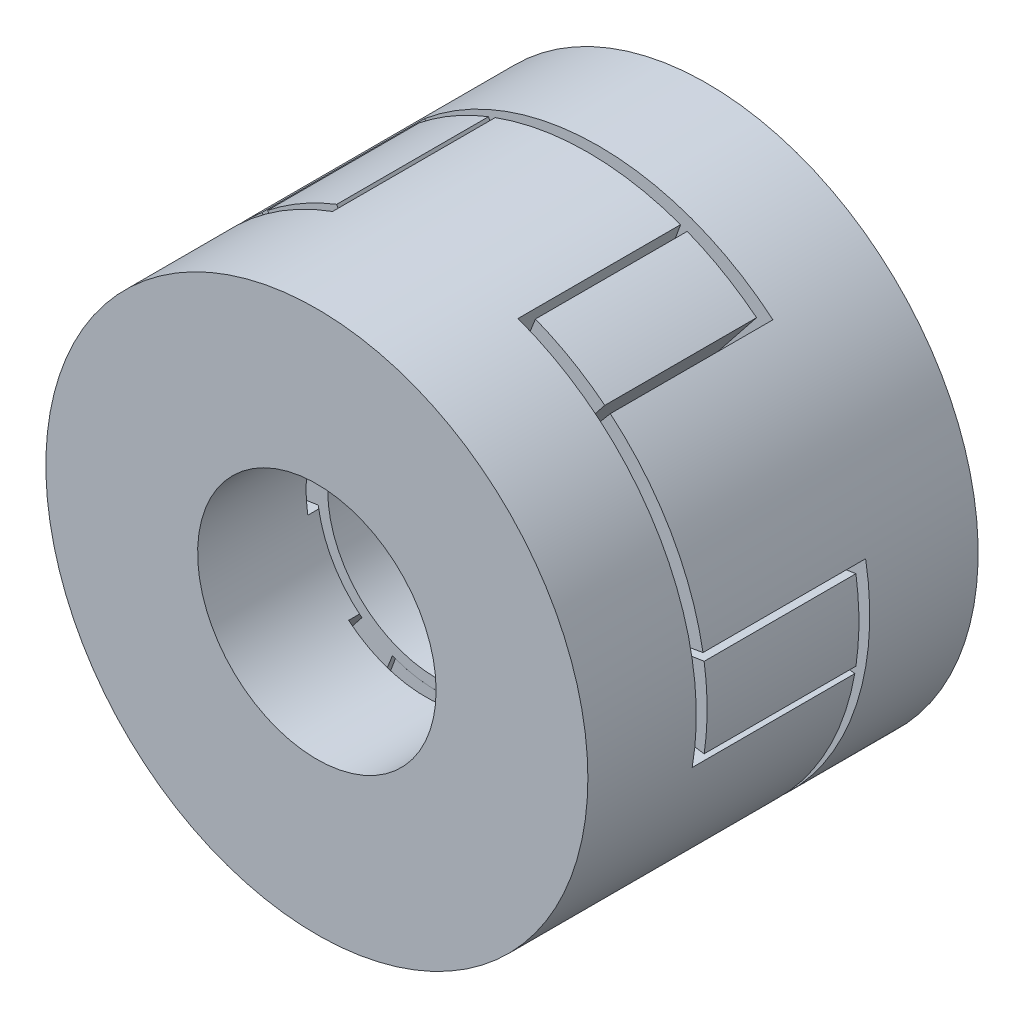
from build123d import *

# Parameters (mm, degrees)
SKETCH_1_R          = 25
SKETCH_1_R_2        = 11
EXTRUDE_1_DEPTH     = 25
CUT_EXTRUDE_1_DEPTH = 15
SKETCH_3_R          = 25
SKETCH_3_R_2        = 11
EXTRUDE_3_DEPTH     = 25
CUT_EXTRUDE_2_DEPTH = 15
SKETCH_5_R          = 25
SKETCH_5_R_2        = 10
EXTRUDE_5_DEPTH     = 14
CUT_EXTRUDE_5_DEPTH = 14


with BuildPart() as part:
    # 草图1 → 凸台-拉伸1 (new body)
    with BuildSketch(Plane.XY):
        Circle(SKETCH_1_R)
        Circle(SKETCH_1_R_2, mode=Mode.SUBTRACT)
    extrude(amount=EXTRUDE_1_DEPTH)

    # 草图2 → 切除-拉伸1 (cut)
    with BuildSketch(Plane(origin=(0, 0, 0), x_dir=(-1, 0, 0), z_dir=(0, 0, -1))):
        with BuildLine():
            Line((-24.620193825, -4.341204442), (-10.832885283, -1.910129954))
            ThreePointArc((-10.832885283, -1.910129954), (-9.526279442, 5.5), (-3.762221577, 10.336618829))
            Line((-3.762221577, 10.336618829), (-8.550503583, 23.49231552))
            ThreePointArc((-8.550503583, 23.49231552), (-16.069690273, 19.151111052), (-21.650635135, 12.49999993))
            ThreePointArc((-21.650635135, 12.49999993), (-24.620193832, 4.341204402), (-24.620193825, -4.341204442))
        make_face()
        with BuildLine():
            Line((8.550503583, 23.49231552), (3.762221577, 10.336618829))
            ThreePointArc((3.762221577, 10.336618829), (9.010672487, 6.3093408), (11, 0))
            ThreePointArc((11, 0), (10.958141679, -0.95871317), (10.832885283, -1.910129954))
            Line((10.832885283, -1.910129954), (24.620193825, -4.341204442))
            ThreePointArc((24.620193825, -4.341204442), (24.904867452, -2.178893569), (25, 0))
            ThreePointArc((25, 0), (24.148145619, 6.470476269), (21.650634949, 12.500000253))
            ThreePointArc((21.650634949, 12.500000253), (16.06969013, 19.151111172), (8.550503583, 23.49231552))
        make_face()
        with BuildLine():
            ThreePointArc((0, -11), (-3.762221577, -10.336618829), (-7.070663707, -8.426488874))
            Line((-7.070663707, -8.426488874), (-16.069690242, -19.151111078))
            ThreePointArc((-16.069690242, -19.151111078), (-8.550503583, -23.49231552), (0, -25))
            Line((0, -25), (0, -11))
        make_face()
        with BuildLine():
            Line((16.069690242, -19.151111078), (7.070663707, -8.426488874))
            ThreePointArc((7.070663707, -8.426488874), (3.762221577, -10.336618829), (0, -11))
            Line((0, -11), (0, -25))
            ThreePointArc((0, -25), (8.550503583, -23.49231552), (16.069690242, -19.151111078))
        make_face()
    extrude(amount=-CUT_EXTRUDE_1_DEPTH, mode=Mode.SUBTRACT)


with BuildPart() as body_2:
    # 草图3 → 凸台-拉伸3 (new body)
    with BuildSketch(Plane(origin=(0, 0, 14), x_dir=(-1, 0, 0), z_dir=(0, 0, -1))):
        Circle(SKETCH_3_R)
        Circle(SKETCH_3_R_2, mode=Mode.SUBTRACT)
    extrude(amount=EXTRUDE_3_DEPTH)

    # 草图4 → 切除-拉伸2 (cut)
    with BuildSketch(Plane.XY.offset(14)):
        with BuildLine():
            Line((-16.069690242, 19.151111078), (-7.070663707, 8.426488874))
            ThreePointArc((-7.070663707, 8.426488874), (-3.762221577, 10.336618829), (0, 11))
            Line((0, 11), (0, 25))
            ThreePointArc((0, 25), (-8.550503583, 23.49231552), (-16.069690242, 19.151111078))
        make_face()
        with BuildLine():
            ThreePointArc((0, 11), (3.762221577, 10.336618829), (7.070663707, 8.426488874))
            Line((7.070663707, 8.426488874), (16.069690242, 19.151111078))
            ThreePointArc((16.069690242, 19.151111078), (8.550503583, 23.49231552), (0, 25))
            Line((0, 25), (0, 11))
        make_face()
        with BuildLine():
            Line((24.620193825, 4.341204442), (10.832885283, 1.910129954))
            ThreePointArc((10.832885283, 1.910129954), (10.958141679, 0.95871317), (11, 0))
            ThreePointArc((11, 0), (9.010672487, -6.3093408), (3.762221577, -10.336618829))
            Line((3.762221577, -10.336618829), (8.550503583, -23.49231552))
            ThreePointArc((8.550503583, -23.49231552), (16.06969013, -19.151111172), (21.650634948, -12.500000253))
            ThreePointArc((21.650634948, -12.500000253), (24.148145619, -6.470476269), (25, 0))
            ThreePointArc((25, 0), (24.904867452, 2.178893569), (24.620193825, 4.341204442))
        make_face()
        with BuildLine():
            Line((-8.550503583, -23.49231552), (-3.762221577, -10.336618829))
            ThreePointArc((-3.762221577, -10.336618829), (-9.526279442, -5.5), (-10.832885283, 1.910129954))
            Line((-10.832885283, 1.910129954), (-24.620193825, 4.341204442))
            ThreePointArc((-24.620193825, 4.341204442), (-24.620193881, -4.341204125), (-21.650635416, -12.499999443))
            ThreePointArc((-21.650635416, -12.499999443), (-16.069690489, -19.151110871), (-8.550503583, -23.49231552))
        make_face()
    extrude(amount=-CUT_EXTRUDE_2_DEPTH, mode=Mode.SUBTRACT)


with BuildPart() as body_3:
    # 草图5 → 凸台-拉伸5 (new body)
    with BuildSketch(Plane(origin=(0, 0, 14), x_dir=(-1, 0, 0), z_dir=(0, 0, -1))):
        Circle(SKETCH_5_R)
        Circle(SKETCH_5_R_2, mode=Mode.SUBTRACT)
    extrude(amount=EXTRUDE_5_DEPTH)

    # 草图6 → 切除-拉伸5 (cut)
    with BuildSketch(Plane(origin=(0, 0, 0), x_dir=(-1, 0, 0), z_dir=(0, 0, -1))):
        with BuildLine():
            Line((-24.725396584, 3.695235278), (-10.879174497, 1.625903522))
            ThreePointArc((-10.879174497, 1.625903522), (-9.526279442, 5.5), (-6.847661003, 8.608689725))
            Line((-6.847661003, 8.608689725), (-15.562865916, 19.565203921))
            ThreePointArc((-15.562865916, 19.565203921), (-18.939124752, 16.318993647), (-21.650635312, 12.499999623))
            ThreePointArc((-21.650635312, 12.499999623), (-23.602225582, 8.242265926), (-24.725396584, 3.695235278))
        make_face()
        with BuildLine():
            Line((-9.162530668, 23.2604392), (-4.031513494, 10.234593248))
            ThreePointArc((-4.031513494, 10.234593248), (-2.051764396, 10.806954375), (0, 11))
            Line((0, 11), (0, 25))
            ThreePointArc((0, 25), (-4.6631009, 24.561259943), (-9.162530668, 23.2604392))
        make_face()
        with BuildLine():
            ThreePointArc((0, 11), (2.051764396, 10.806954375), (4.031513494, 10.234593248))
            Line((4.031513494, 10.234593248), (9.162530668, 23.2604392))
            ThreePointArc((9.162530668, 23.2604392), (4.6631009, 24.561259943), (0, 25))
            Line((0, 25), (0, 11))
        make_face()
        with BuildLine():
            Line((15.562865916, 19.565203921), (6.847661003, 8.608689725))
            ThreePointArc((6.847661003, 8.608689725), (9.526279442, 5.5), (10.879174497, 1.625903522))
            Line((10.879174497, 1.625903522), (24.725396584, 3.695235278))
            ThreePointArc((24.725396584, 3.695235278), (23.60222559, 8.242265901), (21.650635338, 12.499999578))
            ThreePointArc((21.650635338, 12.499999578), (18.939124769, 16.318993627), (15.562865916, 19.565203921))
        make_face()
        with BuildLine():
            Line((24.725396584, -3.695235278), (10.879174497, -1.625903522))
            ThreePointArc((10.879174497, -1.625903522), (9.526279442, -5.5), (6.847661003, -8.608689725))
            Line((6.847661003, -8.608689725), (15.562865916, -19.565203921))
            ThreePointArc((15.562865916, -19.565203921), (18.939124491, -16.31899395), (21.650634913, -12.500000315))
            ThreePointArc((21.650634913, -12.500000315), (23.60222545, -8.242266303), (24.725396584, -3.695235278))
        make_face()
        with BuildLine():
            Line((9.162530668, -23.2604392), (4.031513494, -10.234593248))
            ThreePointArc((4.031513494, -10.234593248), (0, -11), (-4.031513494, -10.234593248))
            Line((-4.031513494, -10.234593248), (-9.162530668, -23.2604392))
            ThreePointArc((-9.162530668, -23.2604392), (-4.6631009, -24.561259943), (0, -25))
            ThreePointArc((0, -25), (4.6631009, -24.561259943), (9.162530668, -23.2604392))
        make_face()
        with BuildLine():
            Line((-15.562865916, -19.565203921), (-6.847661003, -8.608689725))
            ThreePointArc((-6.847661003, -8.608689725), (-9.526279442, -5.5), (-10.879174497, -1.625903522))
            Line((-10.879174497, -1.625903522), (-24.725396584, -3.695235278))
            ThreePointArc((-24.725396584, -3.695235278), (-23.602225599, -8.242265877), (-21.650635365, -12.499999532))
            ThreePointArc((-21.650635365, -12.499999532), (-18.939124786, -16.318993607), (-15.562865916, -19.565203921))
        make_face()
    extrude(amount=-CUT_EXTRUDE_5_DEPTH, mode=Mode.SUBTRACT)


solid = Compound([part.part, body_2.part, body_3.part])
